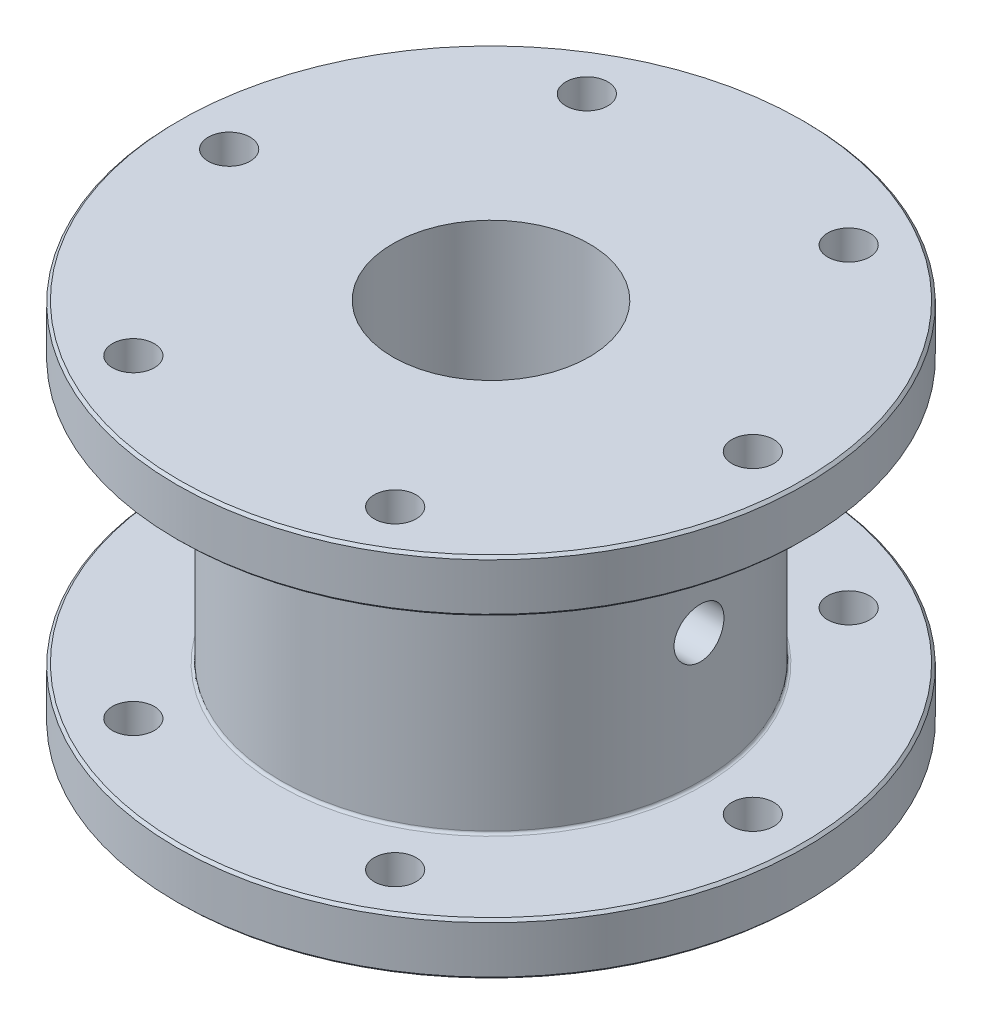
from build123d import *

# Parameters (mm, degrees)
CROQUIS1_R                 = 60
CROQUIS1_R_2               = 18.75
CROQUIS1_R_3               = 4
SALIENTE_EXTRUIR1_DEPTH    = 10
CROQUIS2_R                 = 40
CROQUIS2_R_2               = 18.75
SALIENTE_EXTRUIR2_DEPTH    = 50
CHAFL_N2_SIZE              = 0.5
REDONDEO1_R                = 0.5
CROQUIS3_R                 = 4.7625
CORTAR_EXTRUIR1_DEPTH      = 61
CORTAR_EXTRUIR1_DEPTH_BACK = 61
CHAFL_N3_SIZE              = 0.5
REDONDEO3_R                = 0.5


with BuildPart() as part:
    # Croquis1 → Saliente-Extruir1 (new body)
    with BuildSketch(Plane(origin=(0, 0, 0), x_dir=(1, 0, 0), z_dir=(0, 1, 0))):
        Circle(CROQUIS1_R)
        Circle(CROQUIS1_R_2, mode=Mode.SUBTRACT)
        with Locations((25, -43.301270189)):
            Circle(CROQUIS1_R_3, mode=Mode.SUBTRACT)
        with Locations((-25, -43.301270189)):
            Circle(CROQUIS1_R_3, mode=Mode.SUBTRACT)
        with Locations((-50, 0)):
            Circle(CROQUIS1_R_3, mode=Mode.SUBTRACT)
        with Locations((-25, 43.301270189)):
            Circle(CROQUIS1_R_3, mode=Mode.SUBTRACT)
        with Locations((25, 43.301270189)):
            Circle(CROQUIS1_R_3, mode=Mode.SUBTRACT)
        with Locations((50, 0)):
            Circle(CROQUIS1_R_3, mode=Mode.SUBTRACT)
    saliente_extruir1 = extrude(amount=SALIENTE_EXTRUIR1_DEPTH)

    # Croquis2 → Saliente-Extruir2 (add)
    with BuildSketch(Plane(origin=(0, 10, 0), x_dir=(1, 0, 0), z_dir=(0, 1, 0))):
        Circle(CROQUIS2_R)
        Circle(CROQUIS2_R_2, mode=Mode.SUBTRACT)
    extrude(amount=SALIENTE_EXTRUIR2_DEPTH)

    # Chaflán2
    chafl_n2_edges = [part.edges().sort_by_distance(p)[0] for p in [
        (-60, 0, 0),
        (-60, 10, 0),
    ]]
    chamfer(chafl_n2_edges, length=CHAFL_N2_SIZE)

    # Redondeo1
    redondeo1_edges = [part.edges().sort_by_distance(p)[0] for p in [
        (-40, 10, 0),
    ]]
    fillet(redondeo1_edges, radius=REDONDEO1_R)

    # Croquis3 → Cortar-Extruir1 (cut, two sides)
    with BuildSketch(Plane(origin=(0, 0, 0), x_dir=(0, 0, -1), z_dir=(1, 0, 0))) as cortar_extruir1_sk:
        with Locations((0, 35)):
            Circle(CROQUIS3_R)
    extrude(amount=CORTAR_EXTRUIR1_DEPTH, mode=Mode.SUBTRACT)
    extrude(cortar_extruir1_sk.sketch, amount=-CORTAR_EXTRUIR1_DEPTH_BACK, mode=Mode.SUBTRACT)

    # Simetría1: Saliente-Extruir1 across plane
    add(saliente_extruir1.mirror(Plane.ZX.offset(35)))

    # Chaflán3
    chafl_n3_edges = [part.edges().sort_by_distance(p)[0] for p in [
        (-60, 60, 0),
        (-60, 70, 0),
    ]]
    chamfer(chafl_n3_edges, length=CHAFL_N3_SIZE)

    # Redondeo3
    redondeo3_edges = [part.edges().sort_by_distance(p)[0] for p in [
        (-40, 60, 0),
    ]]
    fillet(redondeo3_edges, radius=REDONDEO3_R)


solid = part.part
